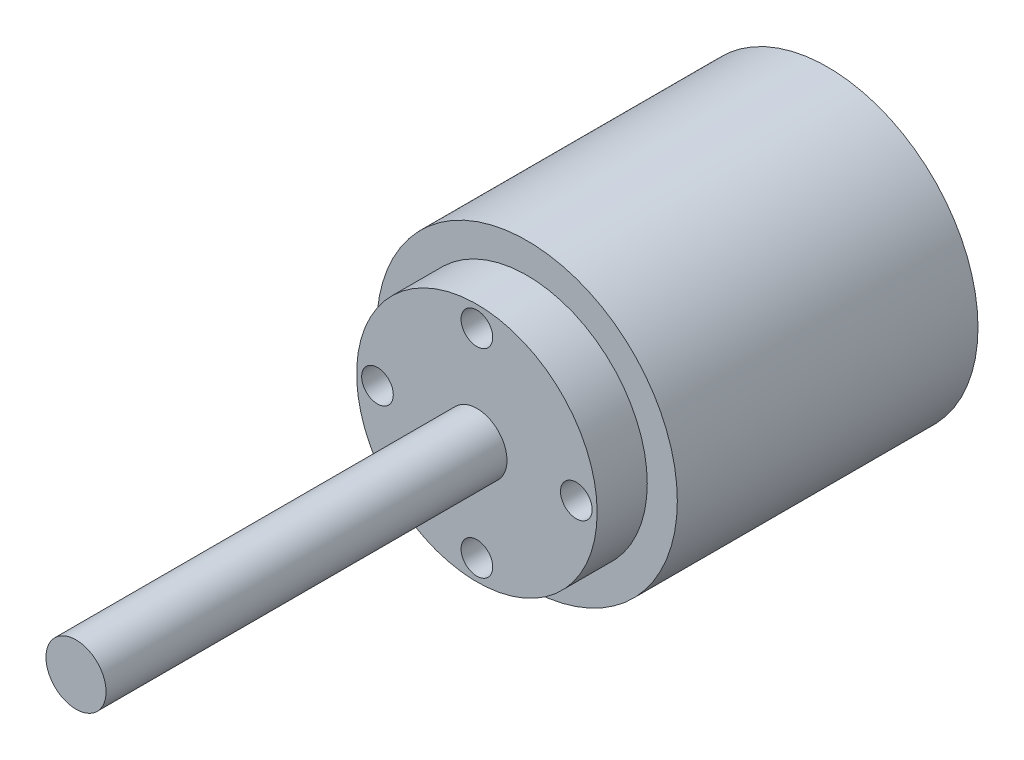
from build123d import *

# Parameters (mm, degrees)
SKETCH1_R           = 15
BOSS_EXTRUDE1_DEPTH = 30
SKETCH2_R           = 12
BOSS_EXTRUDE2_DEPTH = 5
SKETCH4_R           = 1.579295677
CUT_EXTRUDE3_DEPTH  = 3
SKETCH5_R           = 3
BOSS_EXTRUDE3_DEPTH = 40


with BuildPart() as part:
    # Sketch1 → Boss-Extrude1 (new body)
    with BuildSketch(Plane.XY):
        with Locations((5.178689325, -6.92509434)):
            Circle(SKETCH1_R)
    extrude(amount=BOSS_EXTRUDE1_DEPTH)

    # Sketch2 → Boss-Extrude2 (add)
    with BuildSketch(Plane.XY.offset(30)):
        with Locations((5.178689325, -6.92509434)):
            Circle(SKETCH2_R)
    extrude(amount=BOSS_EXTRUDE2_DEPTH)

    # Sketch4 → Cut-Extrude3 (cut)
    with BuildSketch(Plane.XY.offset(35)):
        with Locations((5.178689325, 2.995609984)):
            Circle(SKETCH4_R)
        with Locations((15.099393648, -6.92509434)):
            Circle(SKETCH4_R)
        with Locations((5.178689325, -16.845798663)):
            Circle(SKETCH4_R)
        with Locations((-4.742014998, -6.92509434)):
            Circle(SKETCH4_R)
    extrude(amount=-CUT_EXTRUDE3_DEPTH, mode=Mode.SUBTRACT)

    # Sketch5 → Boss-Extrude3 (add)
    with BuildSketch(Plane.XY.offset(35)):
        with Locations((5.178689325, -6.92509434)):
            Circle(SKETCH5_R)
    extrude(amount=BOSS_EXTRUDE3_DEPTH)


solid = part.part
